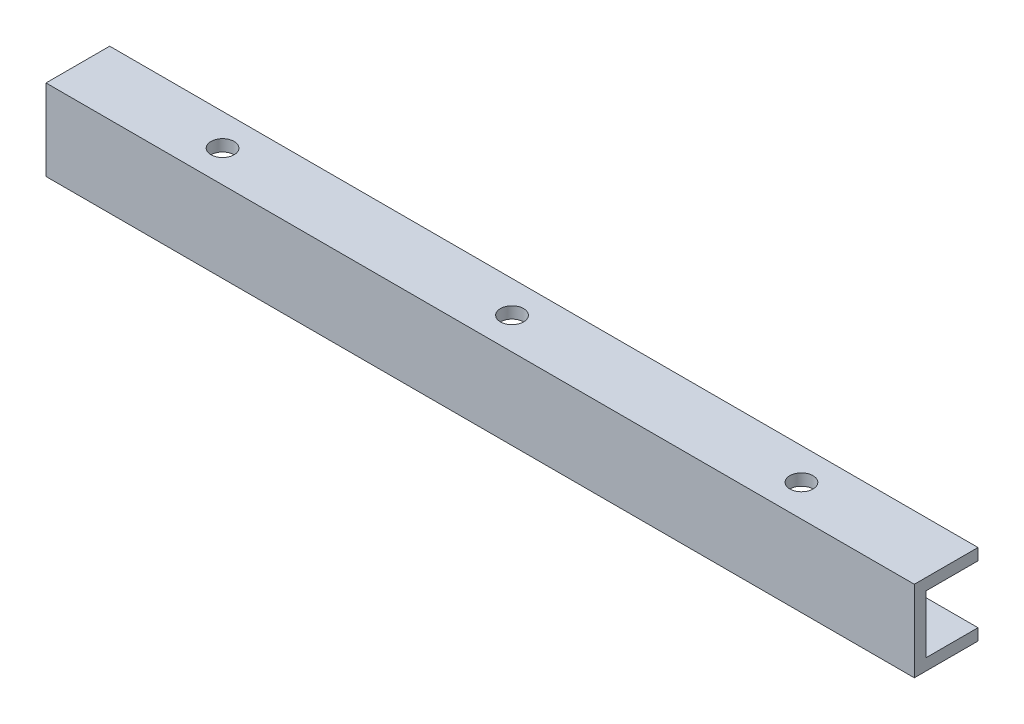
from build123d import *

# Parameters (mm, degrees)
SURFACE_EXTRUDE1_1_BACK  = 150
SURFACE_EXTRUDE1_1_DEPTH = 150
THICKEN1_T1              = 1
THICKEN1_T2              = 1
F_4_0MM_DOWEL_HOLE1_D    = 4


with BuildPart() as body_1:
    # Surface-Extrude1: a surface, the sketch's curves swept straight by 150 mm
    with BuildLine(Plane(origin=(0, 0, 0), x_dir=(0, 0, -1), z_dir=(1, 0, 0)).offset(-SURFACE_EXTRUDE1_1_BACK), mode=Mode.PRIVATE) as surface_extrude1_1_path:
        Line((0, 0), (-10, 0))
        Line((-10, 0), (-10, -12))
        Line((-10, -12), (0, -12))
    surface_extrude1_1 = Shell.extrude(surface_extrude1_1_path.wire(), (1 * SURFACE_EXTRUDE1_1_DEPTH, 0 * SURFACE_EXTRUDE1_1_DEPTH, 0 * SURFACE_EXTRUDE1_1_DEPTH))
    add(Solid.thicken(surface_extrude1_1, THICKEN1_T1))
    add(Solid.thicken(surface_extrude1_1, -THICKEN1_T2))

    # Ø4.0mm Dowel Hole1 (through all)
    with Locations(Plane(origin=(0, 1, 0), x_dir=(1, 0, 0), z_dir=(0, 1, 0))):
        with Locations((-125, -5.5), (-75, -5.5), (-25, -5.5)):
            Hole(F_4_0MM_DOWEL_HOLE1_D / 2)


solid = body_1.part
